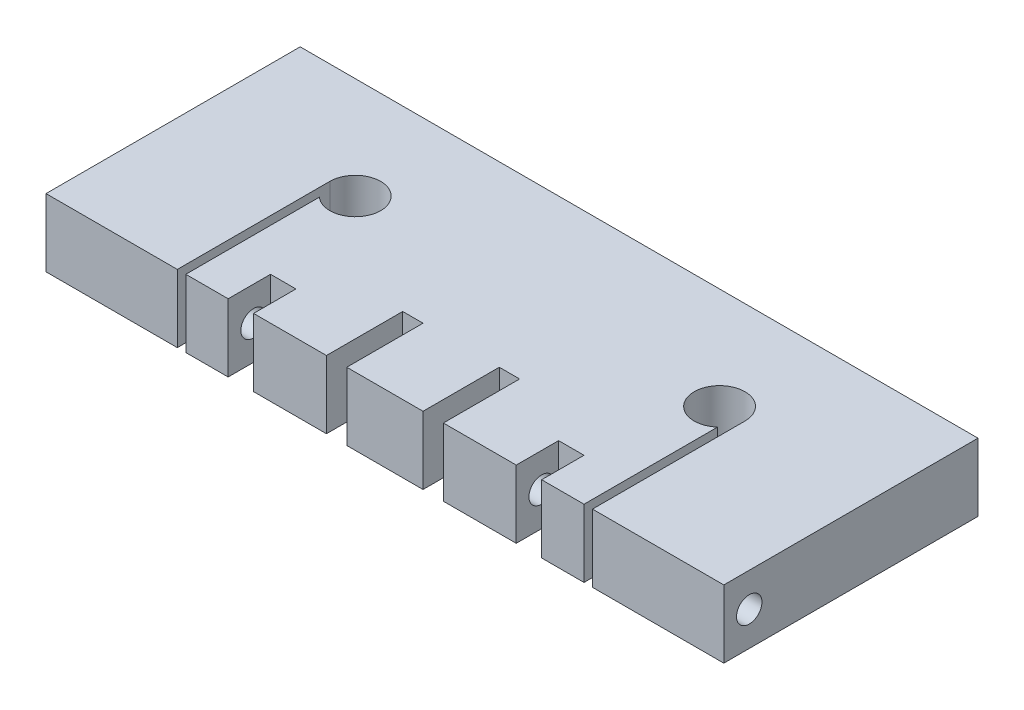
from build123d import *

# Parameters (mm, degrees)
SKETCH_1_W               = 80
SKETCH_1_H               = 30
EXTRUDE_1_DEPTH          = 8
CUT_EXTRUDE_1_DEPTH      = 9
SKETCH_3_W               = 2.4
SKETCH_3_H               = 9
CUT_EXTRUDE_2_DEPTH      = 1
CUT_EXTRUDE_2_DEPTH_BACK = 9
SKETCH_5_R               = 1.5
CUT_EXTRUDE_3_DEPTH      = 32
SKETCH_6_W               = 3
SKETCH_6_H               = 8
CUT_EXTRUDE_5_DEPTH      = 5
SKETCH_7_R               = 1.5
CUT_EXTRUDE_6_DEPTH      = 32


with BuildPart() as part:
    # 草图1 → 凸台-拉伸1 (new body)
    with BuildSketch(Plane(origin=(0, 0, 0), x_dir=(1, 0, 0), z_dir=(0, 1, 0))):
        Rectangle(SKETCH_1_W, SKETCH_1_H)
    extrude(amount=EXTRUDE_1_DEPTH)

    # 草图2 → 切除-拉伸1 (cut, through all)
    with BuildSketch(Plane(origin=(0, 8, 0), x_dir=(1, 0, 0), z_dir=(0, 1, 0))):
        with BuildLine():
            Line((-24.5, 3), (-24.5, -15))
            Line((-24.5, -15), (-23.5, -15))
            Line((-23.5, -15), (-23.5, 0.763932023))
            ThreePointArc((-23.5, 0.763932023), (-18.761387212, 4.224744871), (-24.5, 3))
        make_face()
        with BuildLine():
            Line((23.5, -15), (23.5, 0.763932023))
            ThreePointArc((23.5, 0.763932023), (18.761387212, 4.224744871), (24.5, 3))
            Line((24.5, 3), (24.5, -15))
            Line((24.5, -15), (23.5, -15))
        make_face()
    extrude(amount=-CUT_EXTRUDE_1_DEPTH, mode=Mode.SUBTRACT)

    # 草图3 → 切除-拉伸2 (cut, two sides)
    with BuildSketch(Plane(origin=(0, 8, 0), x_dir=(1, 0, 0), z_dir=(0, 1, 0))) as cut_extrude_2_sk:
        with Locations((-5.7, -10.5)):
            Rectangle(SKETCH_3_W, SKETCH_3_H)
        with Locations((5.7, -10.5)):
            Rectangle(SKETCH_3_W, SKETCH_3_H)
    extrude(amount=CUT_EXTRUDE_2_DEPTH, mode=Mode.SUBTRACT)
    extrude(cut_extrude_2_sk.sketch, amount=-CUT_EXTRUDE_2_DEPTH_BACK, mode=Mode.SUBTRACT)

    # 草图5 → 切除-拉伸3 (cut)
    with BuildSketch(Plane.ZY.offset(40)):
        with Locations((12, 4)):
            Circle(SKETCH_5_R)
    extrude(amount=-CUT_EXTRUDE_3_DEPTH, mode=Mode.SUBTRACT)

    # 草图6 → 切除-拉伸5 (cut)
    with BuildSketch(Plane.XY.offset(15)):
        with Locations((-17, 4)):
            Rectangle(SKETCH_6_W, SKETCH_6_H)
        with Locations((17, 4)):
            Rectangle(SKETCH_6_W, SKETCH_6_H)
    extrude(amount=-CUT_EXTRUDE_5_DEPTH, mode=Mode.SUBTRACT)

    # 草图7 → 切除-拉伸6 (cut)
    with BuildSketch(Plane(origin=(40, 0, 0), x_dir=(0, 0, -1), z_dir=(1, 0, 0))):
        with Locations((-12, 4)):
            Circle(SKETCH_7_R)
    extrude(amount=-CUT_EXTRUDE_6_DEPTH, mode=Mode.SUBTRACT)


solid = part.part
